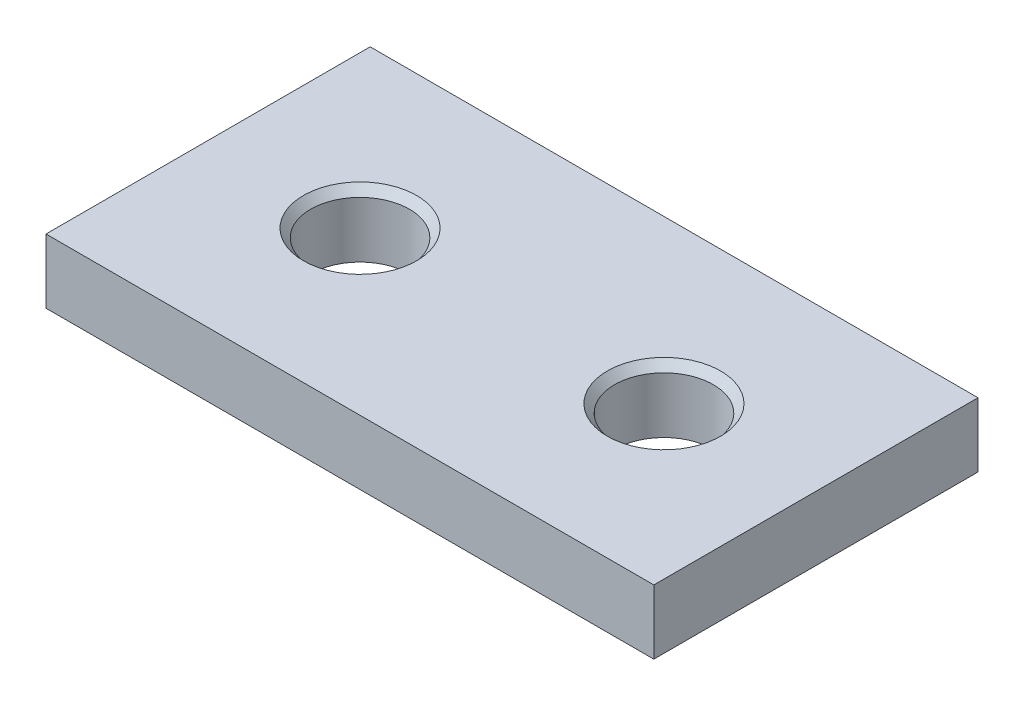
from build123d import *

# Parameters (mm, degrees)
SKETCH1_W                       = 15
SKETCH1_H                       = 8
BOSS_EXTRUDE1_DEPTH             = 1.5875
F_2_CLEARANCE_HOLE1_D           = 2.4384
F_2_CLEARANCE_HOLE1_DEPTH       = 64.75
F_2_CLEARANCE_HOLE1_CSINK_D     = 2.794
F_2_CLEARANCE_HOLE1_CSINK_ANGLE = 82
F_2_CLEARANCE_HOLE1_TIP         = 0.732569267


with BuildPart() as part:
    # Sketch1 → Boss-Extrude1 (new body)
    with BuildSketch(Plane(origin=(0, 0, 0), x_dir=(1, 0, 0), z_dir=(0, 1, 0))):
        Rectangle(SKETCH1_W, SKETCH1_H)
    extrude(amount=BOSS_EXTRUDE1_DEPTH)

    # #2 Clearance Hole1
    with Locations(Plane(origin=(0, 1.5875, 0), x_dir=(1, 0, 0), z_dir=(0, 1, 0))):
        with Locations((-3.75, 0), (3.75, 0)):
            CounterSinkHole(F_2_CLEARANCE_HOLE1_D / 2, F_2_CLEARANCE_HOLE1_CSINK_D / 2, depth=F_2_CLEARANCE_HOLE1_DEPTH, counter_sink_angle=F_2_CLEARANCE_HOLE1_CSINK_ANGLE)
            with Locations((0, 0, -(F_2_CLEARANCE_HOLE1_DEPTH + F_2_CLEARANCE_HOLE1_TIP / 2))):  # 118° drill point
                Cone(0, F_2_CLEARANCE_HOLE1_D / 2, F_2_CLEARANCE_HOLE1_TIP, mode=Mode.SUBTRACT)


solid = part.part
